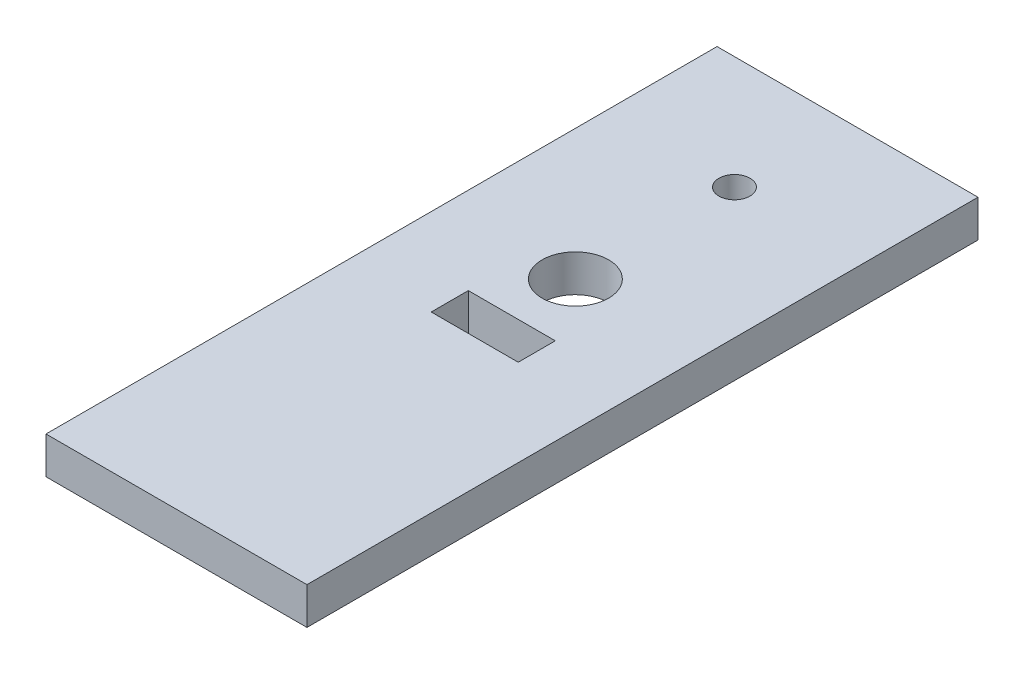
from build123d import *

# Parameters (mm, degrees)
SKETCH1_R           = 5.35
SKETCH1_R_2         = 2.5
BOSS_EXTRUDE1_DEPTH = 5.969
SKETCH2_W           = 42
SKETCH2_H           = 48
BOSS_EXTRUDE2_DEPTH = 5.969


with BuildPart() as part:
    # Sketch1 → Boss-Extrude1 (new body)
    with BuildSketch(Plane(origin=(0, 0, 0), x_dir=(1, 0, 0), z_dir=(0, 1, 0))):
        Polygon((0, 0), (14, 0), (14, 5.969), (28, 5.969), (28, 0), (42, 0), (42, 60), (0, 60), align=None)
        with Locations((21, 16.2)):
            Circle(SKETCH1_R, mode=Mode.SUBTRACT)
        with Locations((21, 41.8)):
            Circle(SKETCH1_R_2, mode=Mode.SUBTRACT)
    extrude(amount=BOSS_EXTRUDE1_DEPTH)

    # Sketch2 → Boss-Extrude2 (add)
    with BuildSketch(Plane(origin=(0, 5.969, 0), x_dir=(1, 0, 0), z_dir=(0, 1, 0))):
        with Locations((21, -24)):
            Rectangle(SKETCH2_W, SKETCH2_H)
    extrude(amount=-BOSS_EXTRUDE2_DEPTH)


solid = part.part
